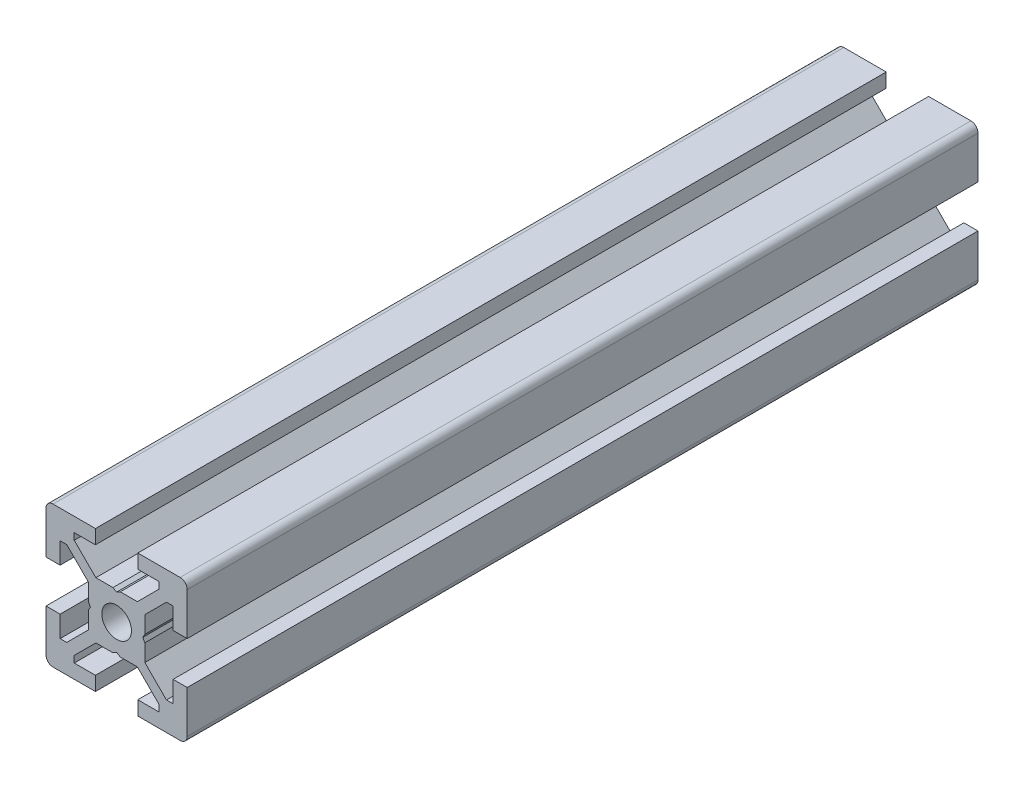
from build123d import *

# Parameters (mm, degrees)
EXTRUDE_1_DEPTH = 112
SKETCH_2_W      = 260
SKETCH_2_H      = 2.1


with BuildPart() as part:
    # ｽｹｯﾁ1 → ﾎﾞｽ - 押し出し1 (new body)
    with BuildSketch(Plane.XY):
        with BuildLine():
            Line((-10, -3), (-10, -9))
            ThreePointArc((-10, -9), (-9.707106781, -9.707106781), (-9, -10))
            Line((-9, -10), (-3, -10))
            Line((-3, -10), (-3, -8))
            Line((-3, -8), (-6, -8))
            Line((-6, -8), (-6, -7.060660172))
            Line((-6, -7.060660172), (-2.939339828, -4))
            Line((-2.939339828, -4), (-0.519615242, -4))
            Line((-0.519615242, -4), (0, -3.7))
            Line((0, -3.7), (0.519615242, -4))
            Line((0.519615242, -4), (2.939339828, -4))
            Line((2.939339828, -4), (6, -7.060660172))
            Line((6, -7.060660172), (6, -8))
            Line((6, -8), (3, -8))
            Line((3, -8), (3, -10))
            Line((3, -10), (9, -10))
            ThreePointArc((9, -10), (9.707106781, -9.707106781), (10, -9))
            Line((10, -9), (10, -3))
            Line((10, -3), (8, -3))
            Line((8, -3), (8, -6))
            Line((8, -6), (7.060660172, -6))
            Line((7.060660172, -6), (4, -2.939339828))
            Line((4, -2.939339828), (4, -0.519615242))
            Line((4, -0.519615242), (3.7, 0))
            Line((3.7, 0), (4, 0.519615242))
            Line((4, 0.519615242), (4, 2.939339828))
            Line((4, 2.939339828), (7.060660172, 6))
            Line((7.060660172, 6), (8, 6))
            Line((8, 6), (8, 3))
            Line((8, 3), (10, 3))
            Line((10, 3), (10, 9))
            ThreePointArc((10, 9), (9.707106781, 9.707106781), (9, 10))
            Line((9, 10), (3, 10))
            Line((3, 10), (3, 8))
            Line((3, 8), (6, 8))
            Line((6, 8), (6, 7.060660172))
            Line((6, 7.060660172), (2.939339828, 4))
            Line((2.939339828, 4), (0.519615242, 4))
            Line((0.519615242, 4), (0, 3.7))
            Line((0, 3.7), (-0.519615242, 4))
            Line((-0.519615242, 4), (-2.939339828, 4))
            Line((-2.939339828, 4), (-6, 7.060660172))
            Line((-6, 7.060660172), (-6, 8))
            Line((-6, 8), (-3, 8))
            Line((-3, 8), (-3, 10))
            Line((-3, 10), (-9, 10))
            ThreePointArc((-9, 10), (-9.707106781, 9.707106781), (-10, 9))
            Line((-10, 9), (-10, 3))
            Line((-10, 3), (-8, 3))
            Line((-8, 3), (-8, 6))
            Line((-8, 6), (-7.060660172, 6))
            Line((-7.060660172, 6), (-4, 2.939339828))
            Line((-4, 2.939339828), (-4, 0.519615242))
            Line((-4, 0.519615242), (-3.7, 0))
            Line((-3.7, 0), (-4, -0.519615242))
            Line((-4, -0.519615242), (-4, -2.939339828))
            Line((-4, -2.939339828), (-7.060660172, -6))
            Line((-7.060660172, -6), (-8, -6))
            Line((-8, -6), (-8, -3))
            Line((-8, -3), (-10, -3))
        make_face()
    extrude(amount=-EXTRUDE_1_DEPTH)

    # ｽｹｯﾁ2 → ｶｯﾄ - 回転1 (revolve, cut)
    with BuildSketch(Plane(origin=(0, 0, 0), x_dir=(0, 0, -1), z_dir=(1, 0, 0))):
        with Locations((130, 1.05)):
            Rectangle(SKETCH_2_W, SKETCH_2_H)
    revolve(axis=Axis((0, 0, -260), (0, 0, 1)), mode=Mode.SUBTRACT)


solid = part.part
